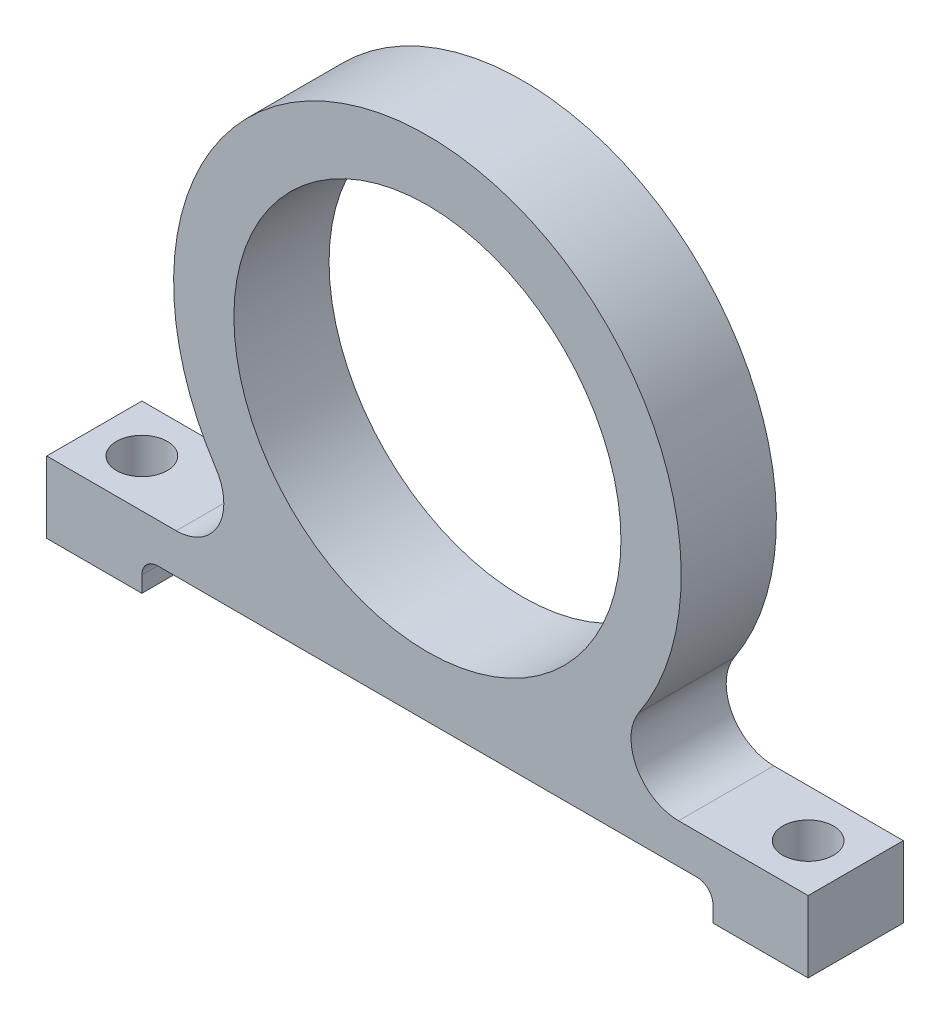
from build123d import *

# Parameters (mm, degrees)
SKETCH1_R             = 12.2
BOSS_EXTRUDE1_DEPTH   = 6
FILLET1_R             = 3
FILLET2_R             = 1
F_3_0MM_DOWEL_HOLE1_D = 3.2


with BuildPart() as part:
    # Sketch1 → Boss-Extrude1 (new body)
    with BuildSketch(Plane.XY):
        with BuildLine():
            Line((18, -16), (-18, -16))
            Line((-18, -16), (-18, -18))
            Line((-18, -18), (-24, -18))
            Line((-24, -18), (-24, -13.5))
            Line((-24, -13.5), (-8.587782019, -13.5))
            ThreePointArc((-8.587782019, -13.5), (0, 16), (8.587782019, -13.5))
            Line((8.587782019, -13.5), (24, -13.5))
            Line((24, -13.5), (24, -18))
            Line((24, -18), (18, -18))
            Line((18, -18), (18, -16))
        make_face()
        Circle(SKETCH1_R, mode=Mode.SUBTRACT)
    extrude(amount=BOSS_EXTRUDE1_DEPTH)

    # Fillet1
    fillet1_edges = [part.edges().sort_by_distance(p)[0] for p in [
        (-8.587782019, -13.5, 3),
        (8.587782019, -13.5, 3),
    ]]
    fillet(fillet1_edges, radius=FILLET1_R)

    # Fillet2
    fillet2_edges = [part.edges().sort_by_distance(p)[0] for p in [
        (18, -16, 3),
        (-18, -16, 3),
    ]]
    fillet(fillet2_edges, radius=FILLET2_R)

    # Ø3.0mm Dowel Hole1 (through all)
    with Locations(Plane(origin=(0, -13.5, 0), x_dir=(1, 0, 0), z_dir=(0, 1, 0))):
        with Locations((-21, -3), (21, -3)):
            Hole(F_3_0MM_DOWEL_HOLE1_D / 2)


solid = part.part
